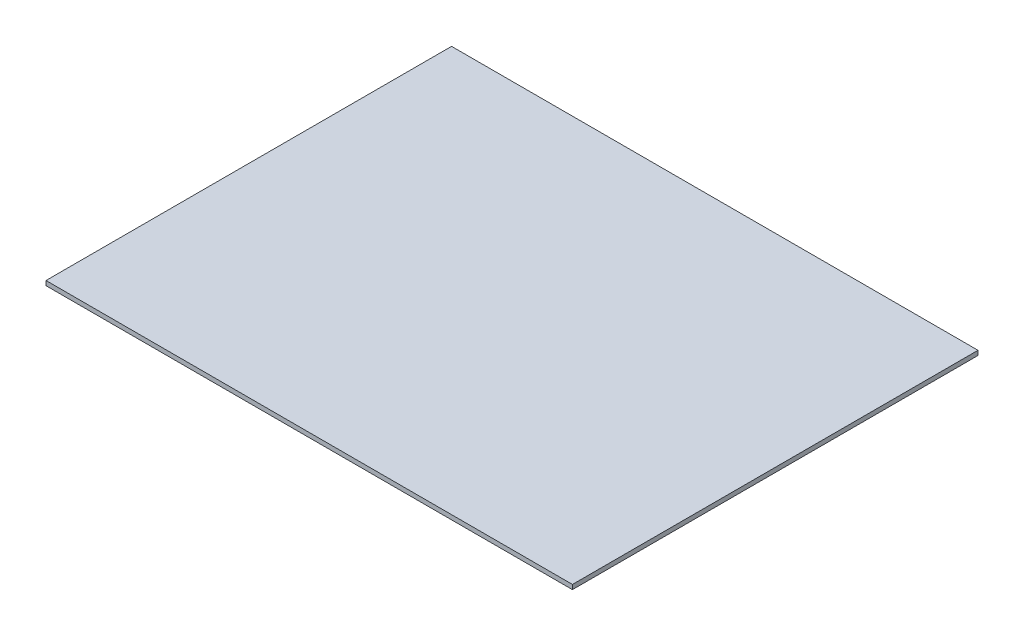
from build123d import *

# Parameters (mm, degrees)
SKETCH_1_W      = 466
SKETCH_1_H      = 359
EXTRUDE_1_DEPTH = 4


with BuildPart() as part:
    # Эскиз1 → Бобышка-Вытянуть1 (new body)
    with BuildSketch(Plane(origin=(0, 0, 0), x_dir=(1, 0, 0), z_dir=(0, 1, 0))):
        Rectangle(SKETCH_1_W, SKETCH_1_H)
    extrude(amount=EXTRUDE_1_DEPTH)


solid = part.part
